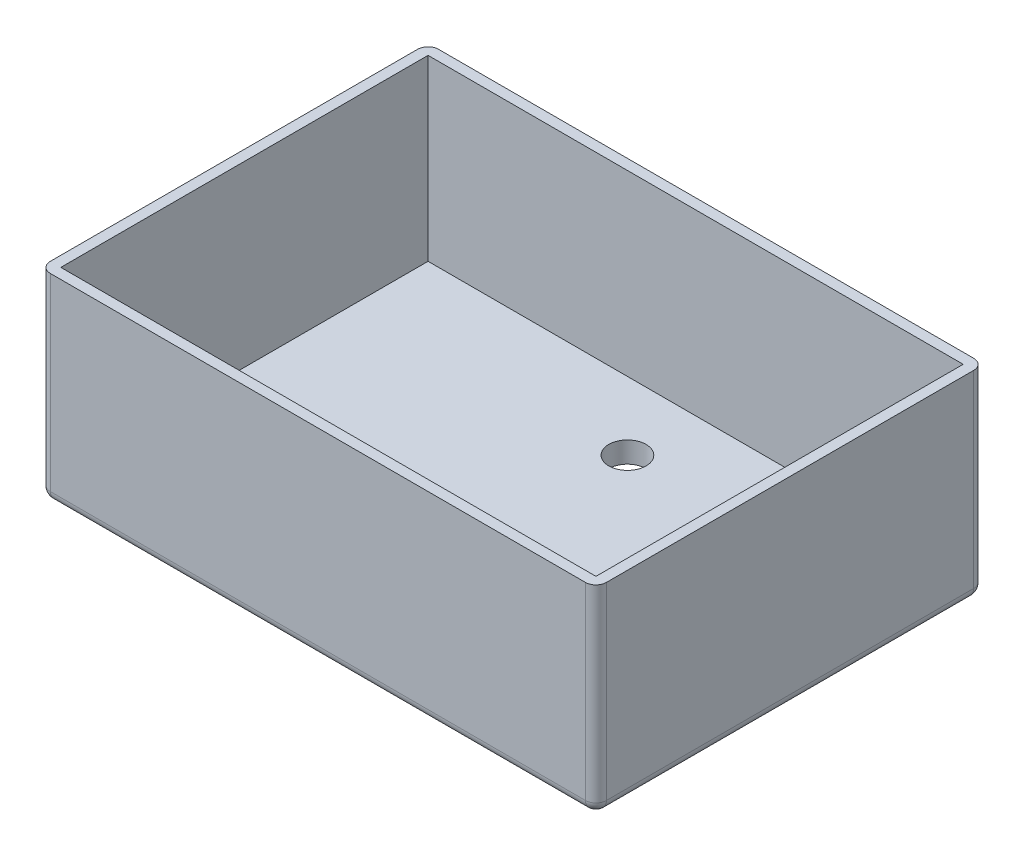
from build123d import *

# Parameters (mm, degrees)
SKETCH1_W           = 265
SKETCH1_H           = 185
BOSS_EXTRUDE1_DEPTH = 95
SKETCH2_W           = 255
SKETCH2_H           = 175
CUT_EXTRUDE1_DEPTH  = 85
CUT_EXTRUDE2_REACH  = 97
SKETCH6_R           = 8.89
FILLET1_R           = 5


with BuildPart() as part:
    # Sketch1 → Boss-Extrude1 (new body)
    with BuildSketch(Plane(origin=(0, 0, 0), x_dir=(1, 0, 0), z_dir=(0, 1, 0))):
        Rectangle(SKETCH1_W, SKETCH1_H)
    extrude(amount=BOSS_EXTRUDE1_DEPTH)

    # Sketch2 → Cut-Extrude1 (cut)
    with BuildSketch(Plane(origin=(0, 95, 0), x_dir=(1, 0, 0), z_dir=(0, 1, 0))):
        Rectangle(SKETCH2_W, SKETCH2_H)
    extrude(amount=-CUT_EXTRUDE1_DEPTH, mode=Mode.SUBTRACT)

    # Sketch6 → Cut-Extrude2 (cut, up to next)
    with BuildSketch(Plane.XZ, mode=Mode.PRIVATE) as cut_extrude2_sk1:
        with Locations((0, 55)):
            Circle(SKETCH6_R)
    cut_extrude2_tool1 = extrude(cut_extrude2_sk1.sketch, amount=-CUT_EXTRUDE2_REACH, mode=Mode.PRIVATE) & part.part
    add(cut_extrude2_tool1.solids().sort_by_distance((0, 0, 55))[0], mode=Mode.SUBTRACT)
    # Sketch6 → Cut-Extrude2 (cut, up to next)
    with BuildSketch(Plane.XZ, mode=Mode.PRIVATE) as cut_extrude2_sk2:
        with Locations((0, -55)):
            Circle(SKETCH6_R)
    cut_extrude2_tool2 = extrude(cut_extrude2_sk2.sketch, amount=-CUT_EXTRUDE2_REACH, mode=Mode.PRIVATE) & part.part
    add(cut_extrude2_tool2.solids().sort_by_distance((0, 0, -55))[0], mode=Mode.SUBTRACT)

    # Fillet1
    fillet1_edges = [part.edges().sort_by_distance(p)[0] for p in [
        (0, 0, 92.5),
        (-132.5, 0, 0),
        (0, 0, -92.5),
        (132.5, 0, 0),
        (132.5, 47.5, 92.5),
        (-132.5, 47.5, 92.5),
        (-132.5, 47.5, -92.5),
        (132.5, 47.5, -92.5),
    ]]
    fillet(fillet1_edges, radius=FILLET1_R)


solid = part.part
